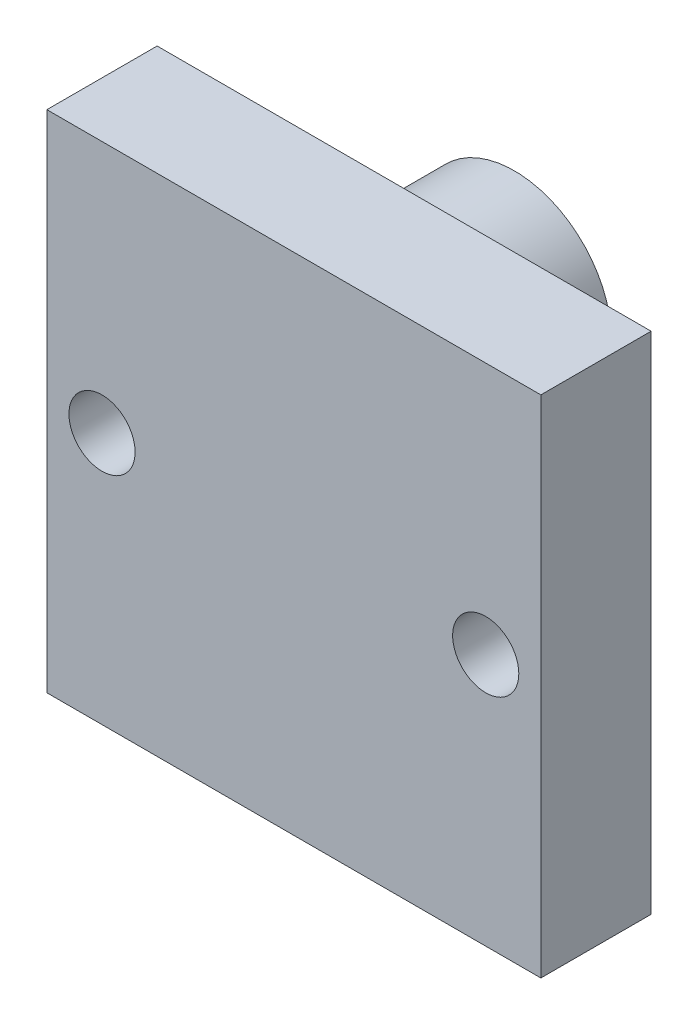
from build123d import *

# Parameters (mm, degrees)
SKETCH1_W           = 22.4
SKETCH1_H           = 22.9
BOSS_EXTRUDE1_DEPTH = 5
SKETCH2_R           = 1.5
CUT_EXTRUDE1_DEPTH  = 5
SKETCH4_R           = 4.4
BOSS_EXTRUDE3_DEPTH = 5


with BuildPart() as part:
    # Sketch1 → Boss-Extrude1 (new body)
    with BuildSketch(Plane.XY):
        Rectangle(SKETCH1_W, SKETCH1_H)
    extrude(amount=BOSS_EXTRUDE1_DEPTH)

    # Sketch2 → Cut-Extrude1 (cut)
    with BuildSketch(Plane.XY.offset(5)):
        with Locations((-8.7, 0)):
            Circle(SKETCH2_R)
        with Locations((8.7, 0)):
            Circle(SKETCH2_R)
    extrude(amount=-CUT_EXTRUDE1_DEPTH, mode=Mode.SUBTRACT)

    # Sketch4 → Boss-Extrude3 (add)
    with BuildSketch(Plane(origin=(0, 0, 0), x_dir=(-1, 0, 0), z_dir=(0, 0, -1))):
        with Locations((0, 5.25)):
            Circle(SKETCH4_R)
    extrude(amount=BOSS_EXTRUDE3_DEPTH)


solid = part.part
